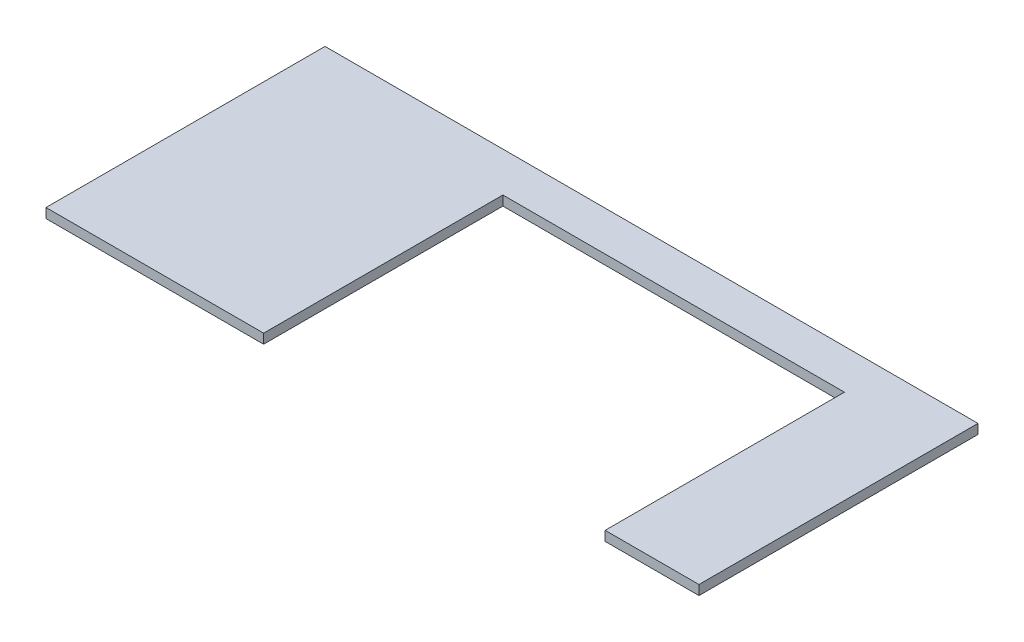
from build123d import *

# Parameters (mm, degrees)
SKETCH1_W           = 1292.86
SKETCH1_H           = 552.45
BOSS_EXTRUDE1_DEPTH = 19.05
SKETCH4_W           = 676.20134
SKETCH4_H           = 473.71
CUT_EXTRUDE3_DEPTH  = 20.05


with BuildPart() as part:
    # Sketch1 → Boss-Extrude1 (new body)
    with BuildSketch(Plane(origin=(0, 0, 0), x_dir=(1, 0, 0), z_dir=(0, 1, 0))):
        with Locations((646.43, 276.225)):
            Rectangle(SKETCH1_W, SKETCH1_H)
    extrude(amount=-BOSS_EXTRUDE1_DEPTH)

    # Sketch4 → Cut-Extrude3 (cut, through all)
    with BuildSketch(Plane(origin=(0, 0, 0), x_dir=(1, 0, 0), z_dir=(0, 1, 0))):
        with Locations((768.98627, 236.855)):
            Rectangle(SKETCH4_W, SKETCH4_H)
    extrude(amount=-CUT_EXTRUDE3_DEPTH, mode=Mode.SUBTRACT)


solid = part.part
